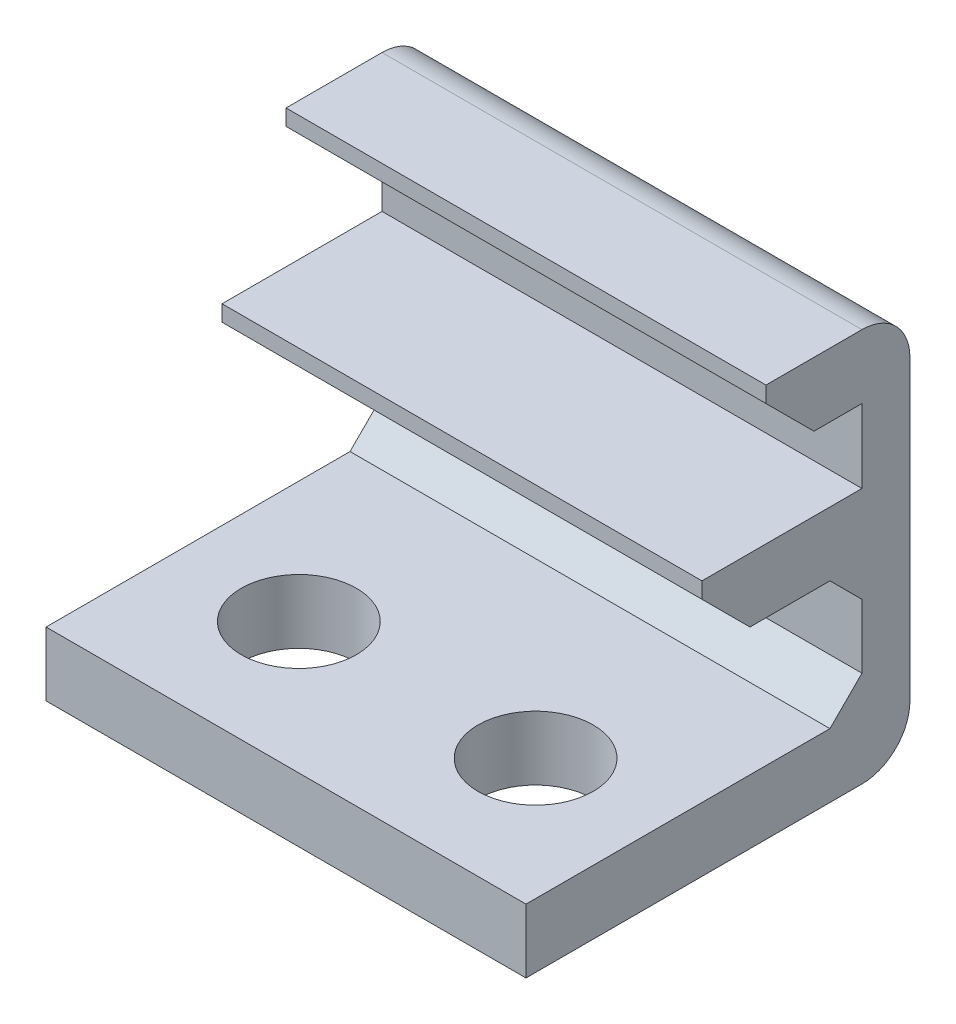
from build123d import *

# Parameters (mm, degrees)
BOSS_EXTRUDE1_DEPTH     = 7.5
CHAMFER1_SIZE           = 1
SKETCH2_R               = 1.8
CUT_EXTRUDE1_DEPTH      = 3
CUT_EXTRUDE1_DEPTH_BACK = 3
FILLET1_R               = 1.5
CHAMFER2_SIZE           = 1.5


with BuildPart() as part:
    # Sketch1 → Boss-Extrude1 (new body, symmetric)
    with BuildSketch(Plane(origin=(0, 0, 0), x_dir=(0, 0, -1), z_dir=(1, 0, 0))):
        Polygon((-5.25, -4.15), (-5.25, -6.15), (6.75, -6.15), (6.75, 6.15), (2.25, 6.15), (2.25, 4.15), (5.25, 4.15), (5.25, 1.85), (0.25, 1.85), (0.25, -0.15), (5.25, -0.15), (5.25, -4.15), align=None)
    extrude(amount=BOSS_EXTRUDE1_DEPTH, both=True)

    # Chamfer1
    chamfer1_edges = [part.edges().sort_by_distance(p)[0] for p in [
        (0, -4.15, -5.25),
        (0, -0.15, -5.25),
    ]]
    chamfer(chamfer1_edges, length=CHAMFER1_SIZE)

    # Sketch2 → Cut-Extrude1 (cut, two sides)
    with BuildSketch(Plane(origin=(0, -4.15, 0), x_dir=(1, 0, 0), z_dir=(0, 1, 0))) as cut_extrude1_sk:
        with Locations((-3.7, -1.15)):
            Circle(SKETCH2_R)
        with Locations((3.7, -1.15)):
            Circle(SKETCH2_R)
    extrude(amount=CUT_EXTRUDE1_DEPTH, mode=Mode.SUBTRACT)
    extrude(cut_extrude1_sk.sketch, amount=-CUT_EXTRUDE1_DEPTH_BACK, mode=Mode.SUBTRACT)

    # Fillet1
    fillet1_edges = [part.edges().sort_by_distance(p)[0] for p in [
        (0, 6.15, -6.75),
        (0, -6.15, -6.75),
    ]]
    fillet(fillet1_edges, radius=FILLET1_R)

    # Chamfer2
    chamfer2_edges = [part.edges().sort_by_distance(p)[0] for p in [
        (0, 4.15, -2.25),
        (0, -0.15, -0.25),
    ]]
    chamfer(chamfer2_edges, length=CHAMFER2_SIZE)


solid = part.part
